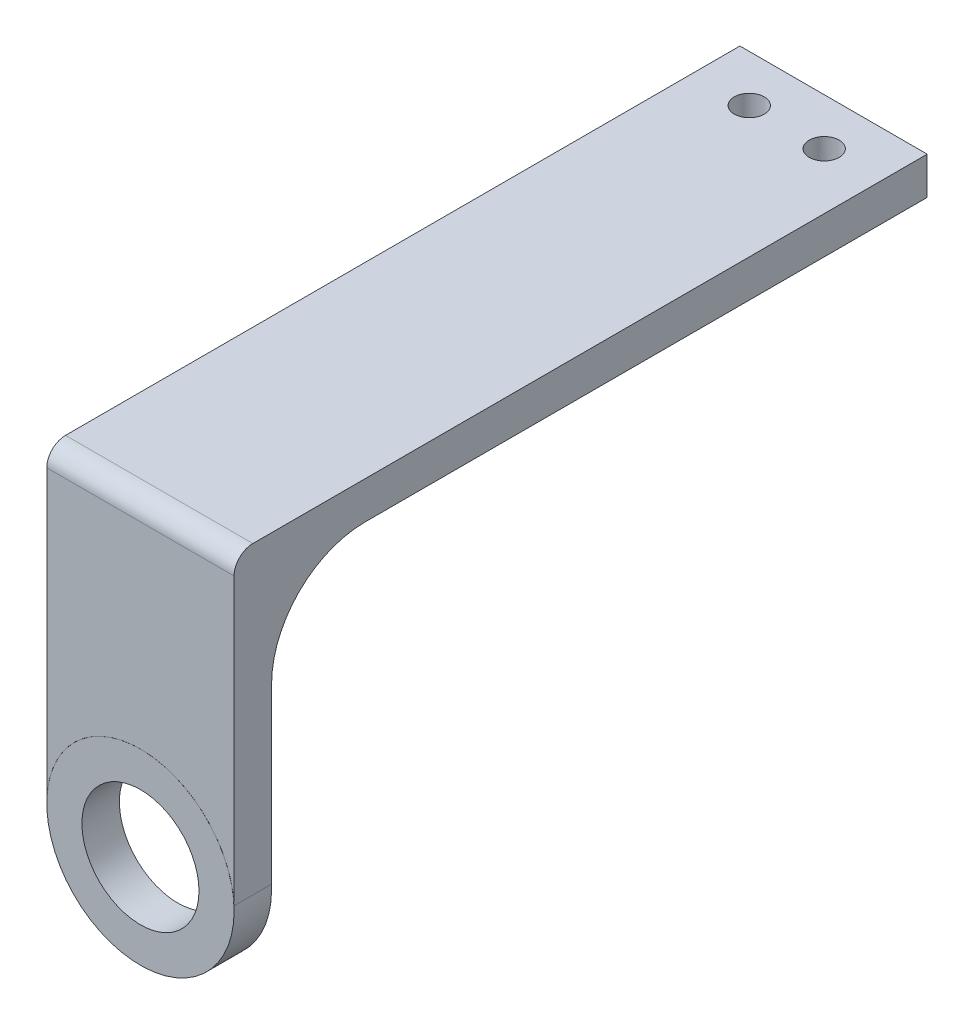
from build123d import *

# Parameters (mm, degrees)
SALIENTE_EXTRUIR1_DEPTH   = 4
CROQUIS1_R                = 10
CROQUIS1_R_2              = 6.25
SALIENTE_EXTRUIR1_2_DEPTH = 4
CROQUIS2_W                = 20
CROQUIS2_H                = 4
SALIENTE_EXTRUIR2_DEPTH   = 70
CROQUIS3_R                = 1.6
CORTAR_EXTRUIR1_DEPTH     = 10
REDONDEO1_R               = 10
REDONDEO2_R               = 2


with BuildPart() as part:
    # Croquis1 → Saliente-Extruir1 (new body)
    with BuildSketch(Plane.XY):
        with BuildLine():
            Line((-10, 0), (-10, 33))
            Line((-10, 33), (10, 33))
            Line((10, 33), (10, 0.502965573))
            ThreePointArc((10, 0.502965573), (-0.245237938, 10.00316168), (-10, 0))
        make_face()
    extrude(amount=SALIENTE_EXTRUIR1_DEPTH)

    # Croquis2 → Saliente-Extruir2 (add)
    with BuildSketch(Plane(origin=(0, 0, 0), x_dir=(-1, 0, 0), z_dir=(0, 0, -1))):
        with Locations((0, 31)):
            Rectangle(CROQUIS2_W, CROQUIS2_H)
    extrude(amount=SALIENTE_EXTRUIR2_DEPTH)

    # Croquis3 → Cortar-Extruir1 (cut)
    with BuildSketch(Plane(origin=(0, 33, 0), x_dir=(1, 0, 0), z_dir=(0, 1, 0))):
        with Locations((-4, 65)):
            Circle(CROQUIS3_R)
        with Locations((4, 65)):
            Circle(CROQUIS3_R)
    extrude(amount=-CORTAR_EXTRUIR1_DEPTH, mode=Mode.SUBTRACT)

    # Redondeo1
    redondeo1_edges = [part.edges().sort_by_distance(p)[0] for p in [
        (0, 29, 0),
    ]]
    fillet(redondeo1_edges, radius=REDONDEO1_R)

    # Redondeo2
    redondeo2_edges = [part.edges().sort_by_distance(p)[0] for p in [
        (0, 33, 4),
    ]]
    fillet(redondeo2_edges, radius=REDONDEO2_R)


with BuildPart() as body_2:
    # Croquis1 → Saliente-Extruir1 2 (new body)
    with BuildSketch(Plane.XY):
        Circle(CROQUIS1_R)
        Circle(CROQUIS1_R_2, mode=Mode.SUBTRACT)
    extrude(amount=SALIENTE_EXTRUIR1_2_DEPTH)


solid = Compound([part.part, body_2.part])
